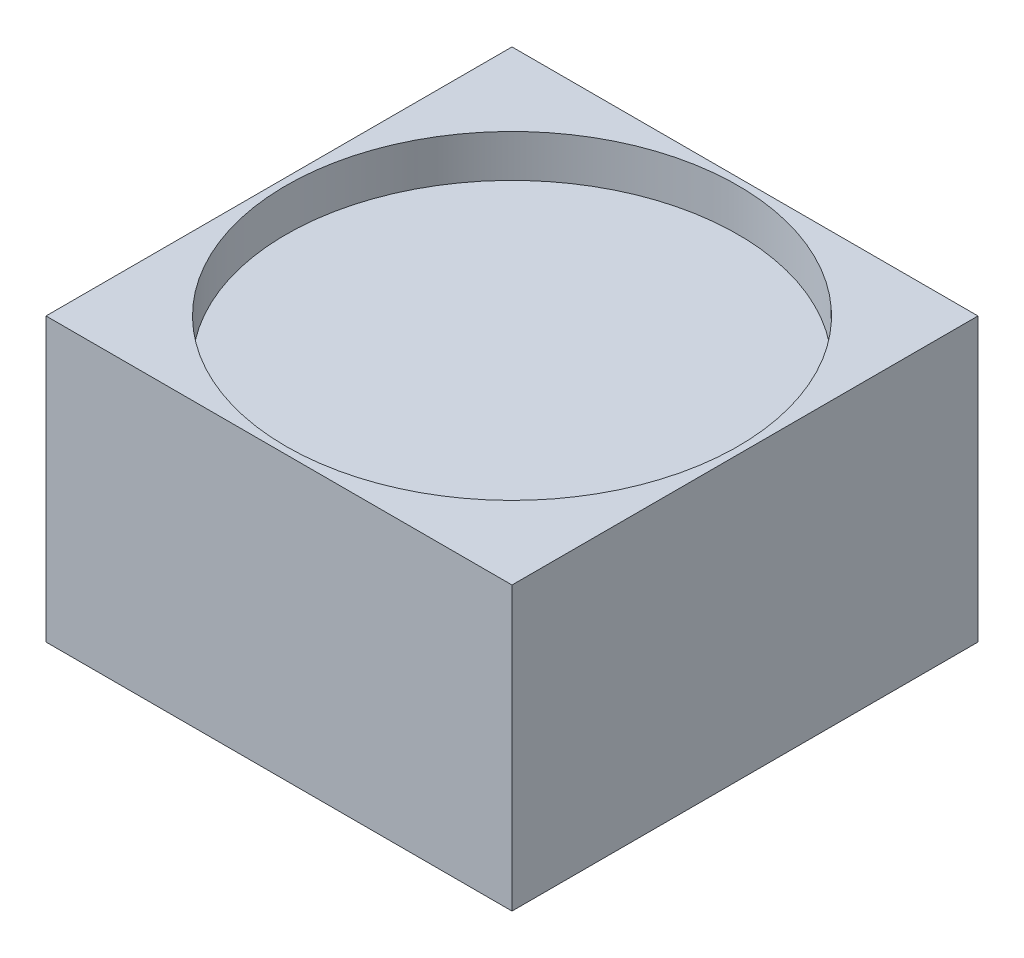
from build123d import *

# Parameters (mm, degrees)
SKETCH1_W           = 33
SKETCH1_H           = 33
BOSS_EXTRUDE1_DEPTH = 20
SKETCH2_R           = 16
CUT_EXTRUDE1_DEPTH  = 3
SKETCH3_R           = 1
CUT_EXTRUDE2_DEPTH  = 2
FILLET1_R           = 1


with BuildPart() as part:
    # Sketch1 → Boss-Extrude1 (new body)
    with BuildSketch(Plane(origin=(0, 0, 0), x_dir=(1, 0, 0), z_dir=(0, 1, 0))):
        Rectangle(SKETCH1_W, SKETCH1_H)
    extrude(amount=BOSS_EXTRUDE1_DEPTH)

    # Sketch2 → Cut-Extrude1 (cut)
    with BuildSketch(Plane(origin=(0, 20, 0), x_dir=(1, 0, 0), z_dir=(0, 1, 0))):
        Circle(SKETCH2_R)
    extrude(amount=-CUT_EXTRUDE1_DEPTH, mode=Mode.SUBTRACT)

    # Sketch3 → Cut-Extrude2 (cut)
    with BuildSketch(Plane.XZ):
        Circle(SKETCH3_R)
    extrude(amount=-CUT_EXTRUDE2_DEPTH, mode=Mode.SUBTRACT)

    # Fillet1
    fillet1_edges = [part.edges().sort_by_distance(p)[0] for p in [
        (-1, 2, 0),
    ]]
    fillet(fillet1_edges, radius=FILLET1_R)


solid = part.part
